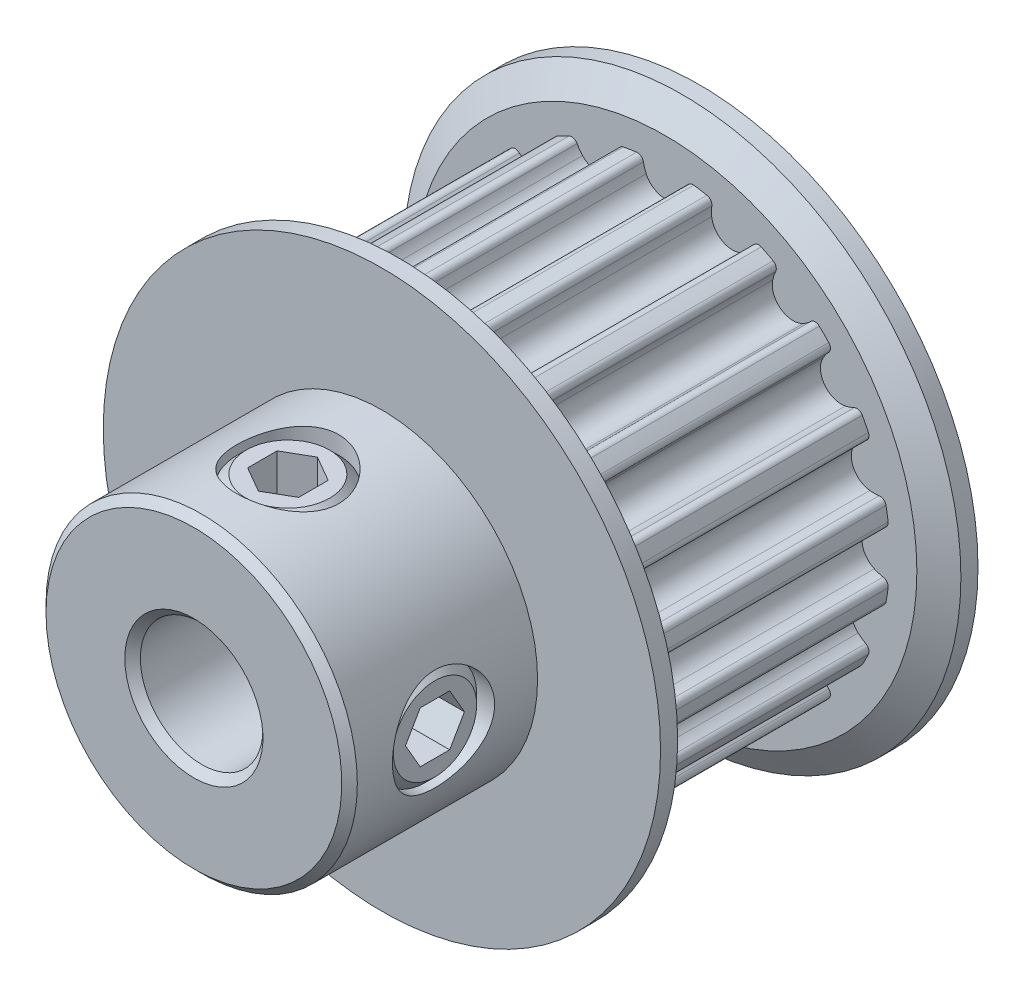
from build123d import *

# Parameters (mm, degrees)
CUT_EXTRUDE1_START = 1.245
CUT_EXTRUDE1_DEPTH = 10.16
CIRPATTERN1_COUNT  = 20
SKETCH4_R          = 2.0828
CUT_EXTRUDE2_DEPTH = 20.096877873
CUT_EXTRUDE3_DEPTH = 1.5621
CIRPATTERN2_COUNT  = 2
CIRPATTERN2_ANGLE  = 90
CHAMFER1_SIZE      = 0.3175


with BuildPart() as part:
    # Sketch2 → Revolve1 (revolve)
    with BuildSketch(Plane(origin=(0, 0, 0), x_dir=(0, 0, -1), z_dir=(1, 0, 0)), mode=Mode.PRIVATE) as revolve1_sk:
        Polygon((-10.31, 2.5), (10.31, 2.5), (10.31, 11.3665), (9.6125, 11.3665), (8.915, 10.268), (8.915, 9.1695), (-1.245, 9.1695), (-1.245, 10.268), (-1.9425, 11.3665), (-2.64, 11.3665), (-2.64, 6.35), (-10.31, 6.35), align=None)
    revolve(revolve1_sk.sketch.rotate(Axis((0, 0, 10.31), (0, 0, -1)), 90), axis=Axis((0, 0, 10.31), (0, 0, -1)))

    # Sketch3 → Cut-Extrude1 (cut)
    with BuildSketch(Plane.XY.offset(CUT_EXTRUDE1_START)):
        with BuildLine():
            Line((3.709120542, 11.3665), (-3.709120542, 11.3665))
            Line((-3.709120542, 11.3665), (-2.844572999, 8.717117339))
            ThreePointArc((-2.844572999, 8.717117339), (-2.013436622, 8.945714238), (-1.164506748, 9.095254493))
            ThreePointArc((-1.164506748, 9.095254493), (-0.984686536, 9.048711247), (-0.886605127, 8.89097216))
            ThreePointArc((-0.886605127, 8.89097216), (-0.841637456, 8.705907931), (-0.773880597, 8.527919538))
            ThreePointArc((-0.773880597, 8.527919538), (0, 8.0295), (0.773880597, 8.527919538))
            ThreePointArc((0.773880597, 8.527919538), (0.841637456, 8.705907931), (0.886605127, 8.89097216))
            ThreePointArc((0.886605127, 8.89097216), (0.984686536, 9.048711247), (1.164506748, 9.095254493))
            ThreePointArc((1.164506748, 9.095254493), (2.013436622, 8.945714238), (2.844572999, 8.717117339))
            Line((2.844572999, 8.717117339), (3.709120542, 11.3665))
        make_face()
    cut_extrude1 = extrude(amount=-CUT_EXTRUDE1_DEPTH, mode=Mode.SUBTRACT)

    # CirPattern1: Cut-Extrude1 ×20 about axis
    cirpattern1_axis = Axis((0, 0, 0), (0, 0, 1))
    for i in range(1, CIRPATTERN1_COUNT):
        add(cut_extrude1.rotate(cirpattern1_axis, i * 360 / CIRPATTERN1_COUNT), mode=Mode.SUBTRACT)

    # Sketch4 → Cut-Extrude2 (cut, through all)
    with BuildSketch(Plane(origin=(0, 0, 0), x_dir=(0, -1, 0), z_dir=(1, 0, 0))):
        with Locations(Location((0, -6.475, 0), (0, 0, 270))):
            Circle(SKETCH4_R)
    cut_extrude2 = extrude(amount=CUT_EXTRUDE2_DEPTH, mode=Mode.SUBTRACT)

    # Sketch5 → Revolve2 (revolve)
    with BuildSketch(Plane.XY.offset(6.475)):
        Polygon((2.5, -1.7018), (2.5, 0), (5.99870354, 0), (5.99870354, -1.7018), (5.61770354, -2.0828), (2.881, -2.0828), align=None)
    revolve2 = revolve(axis=Axis((2.5, 0, 6.475), (1, 0, 0)))

    # Sketch6 → Cut-Extrude3 (cut)
    with BuildSketch(Plane(origin=(5.99870354, 5.384140679, 0), x_dir=(0, -1, 0), z_dir=(-1, 0, 0))):
        Polygon((5.384140679, 7.677505141), (4.342740679, 7.07625257), (4.342740679, 5.87374743), (5.384140679, 5.272494859), (6.425540679, 5.87374743), (6.425540679, 7.07625257), align=None)
    cut_extrude3 = extrude(amount=CUT_EXTRUDE3_DEPTH, mode=Mode.SUBTRACT)

    # CirPattern2: Cut-Extrude2, Revolve2, Cut-Extrude3 ×2 about axis
    cirpattern2_axis = Axis((0, 0, 0), (0, 0, 1))
    add([cut_extrude2.rotate(cirpattern2_axis, i * CIRPATTERN2_ANGLE / (CIRPATTERN2_COUNT - 1)) for i in range(1, CIRPATTERN2_COUNT)], mode=Mode.SUBTRACT)
    add([revolve2.rotate(cirpattern2_axis, i * CIRPATTERN2_ANGLE / (CIRPATTERN2_COUNT - 1)) for i in range(1, CIRPATTERN2_COUNT)])
    add([cut_extrude3.rotate(cirpattern2_axis, i * CIRPATTERN2_ANGLE / (CIRPATTERN2_COUNT - 1)) for i in range(1, CIRPATTERN2_COUNT)], mode=Mode.SUBTRACT)

    # Chamfer1
    chamfer1_edges = [part.edges().sort_by_distance(p)[0] for p in [
        (-6.35, 0, 10.31),
        (-2.5, 0, 10.31),
    ]]
    chamfer(chamfer1_edges, length=CHAMFER1_SIZE)


solid = part.part
